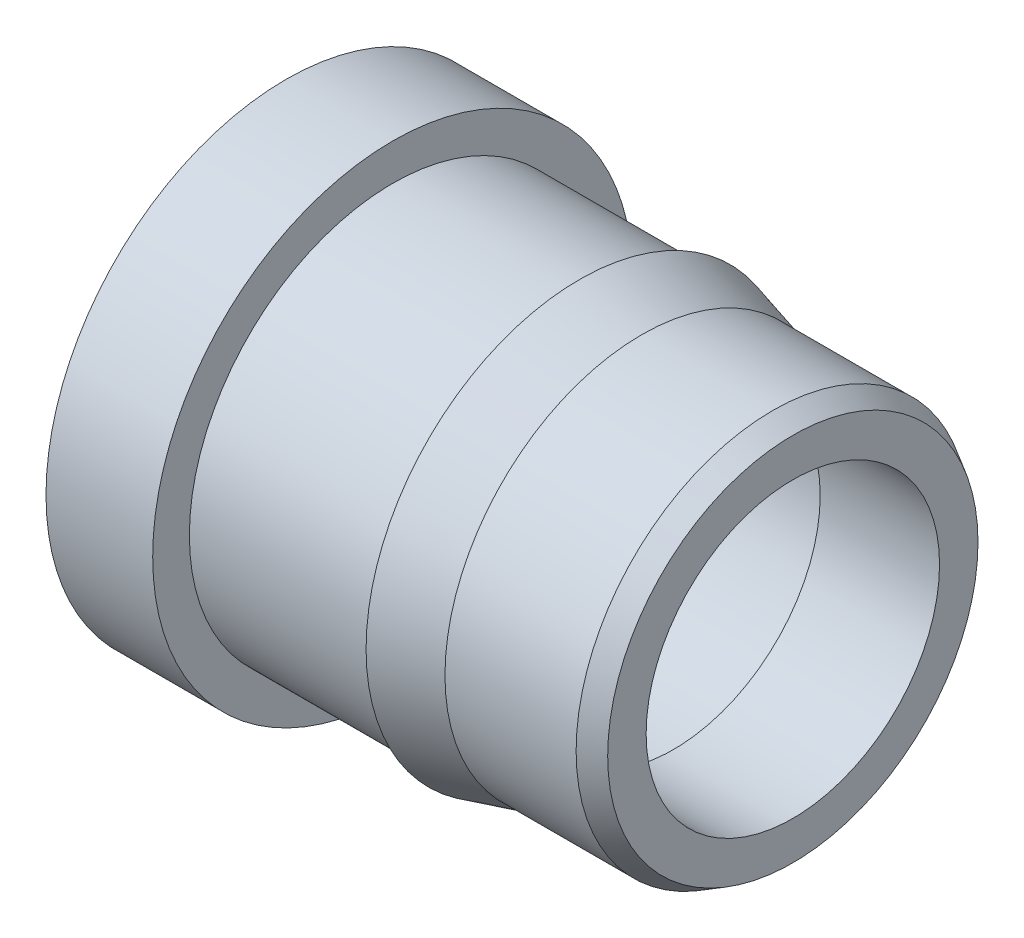
from build123d import *

# Parameters (mm, degrees)
HOLE1_D     = 1.2954
HOLE1_DEPTH = 1.4224
HOLE1_TIP   = 0.389177423
HOLE2_D     = 1.1176
HOLE2_DEPTH = 1.9304
HOLE2_TIP   = 0.335760914


with BuildPart() as part:
    # Sketch1 → RevolutionAngle1 (revolve)
    with BuildSketch(Plane.XY):
        Polygon((0, 0), (0, 0.9144), (0.4064, 0.9144), (0.4064, 0.7747), (1.1176, 0.7747), (1.1176, 0.8128), (1.354585226, 0.7493), (1.8542, 0.7493), (1.9304, 0.705305909), (1.9304, 0), align=None)
    revolve(axis=Axis((0, 0, 0), (1, 0, 0)))

    # Hole1
    with Locations(Plane.ZY):
        with Locations((0, 0)):
            Hole(HOLE1_D / 2, depth=HOLE1_DEPTH)
            with Locations((0, 0, -(HOLE1_DEPTH + HOLE1_TIP / 2))):  # 118° drill point
                Cone(0, HOLE1_D / 2, HOLE1_TIP, mode=Mode.SUBTRACT)

    # Hole2
    with Locations(Plane(origin=(1.9304, 0, 0), x_dir=(0, 0, 1), z_dir=(1, 0, 0))):
        with Locations((0, 0)):
            Hole(HOLE2_D / 2, depth=HOLE2_DEPTH)
            with Locations((0, 0, -(HOLE2_DEPTH + HOLE2_TIP / 2))):  # 118° drill point
                Cone(0, HOLE2_D / 2, HOLE2_TIP, mode=Mode.SUBTRACT)


solid = part.part
